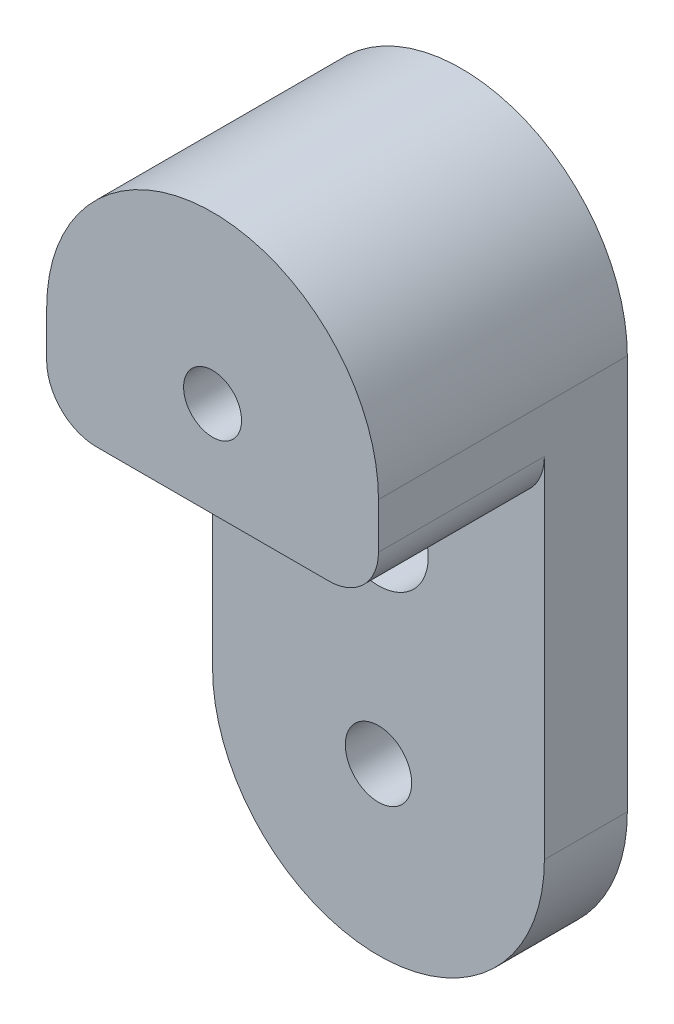
from build123d import *

# Parameters (mm, degrees)
SKETCH1_R           = 2
SKETCH1_R_2         = 3
BOSS_EXTRUDE1_DEPTH = 5
SKETCH1_3_R         = 1.74625
BOSS_EXTRUDE2_DEPTH = 15
FILLET1_R           = 3


with BuildPart() as part:
    # Sketch1 → Boss-Extrude1 (new body)
    with BuildSketch(Plane.XY):
        with BuildLine():
            Line((10, -23.8), (10, -5.75))
            Line((10, -5.75), (-10, -5.75))
            Line((-10, -5.75), (-10, -23.8))
            ThreePointArc((-10, -23.8), (0, -33.8), (10, -23.8))
        make_face()
        with Locations((0, -23.8)):
            Circle(SKETCH1_R, mode=Mode.SUBTRACT)
        with Locations((0, -11.5)):
            Circle(SKETCH1_R_2, mode=Mode.SUBTRACT)
    extrude(amount=BOSS_EXTRUDE1_DEPTH)

    # Sketch1_3 → Boss-Extrude2 (add)
    with BuildSketch(Plane.XY):
        with BuildLine():
            Line((10, -5.75), (10, 0))
            ThreePointArc((10, 0), (0, 10), (-10, 0))
            Line((-10, 0), (-10, -5.75))
            Line((-10, -5.75), (10, -5.75))
        make_face()
        Circle(SKETCH1_3_R, mode=Mode.SUBTRACT)
    extrude(amount=BOSS_EXTRUDE2_DEPTH)

    # Fillet1
    fillet1_edges = [part.edges().sort_by_distance(p)[0] for p in [
        (10, -5.75, 10),
        (-10, -5.75, 10),
    ]]
    fillet(fillet1_edges, radius=FILLET1_R)


solid = part.part
